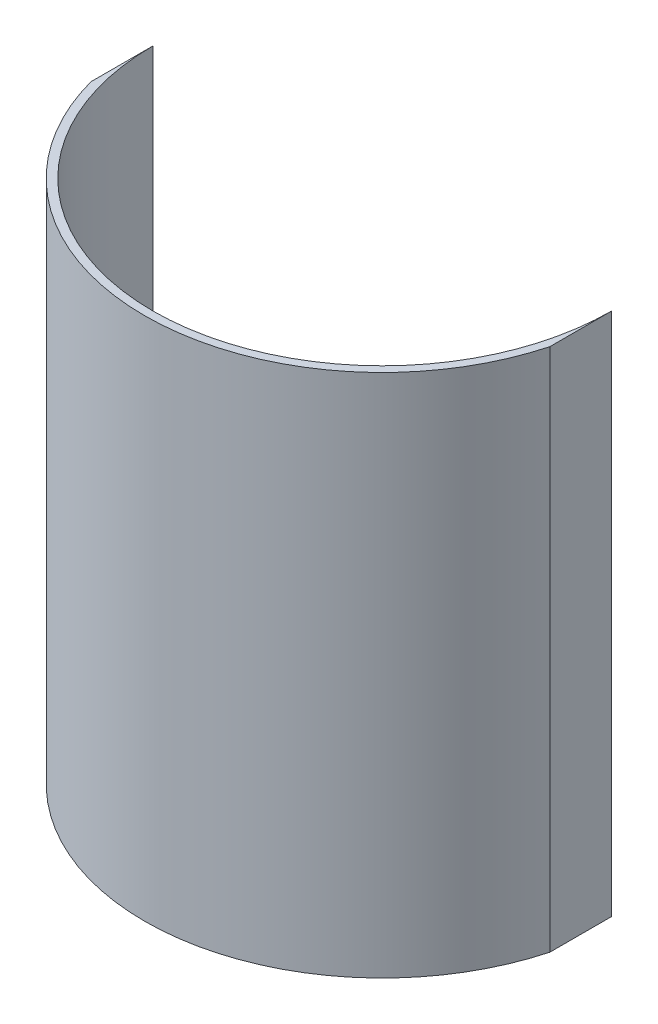
from build123d import *

# Parameters (mm, degrees)
BOSS_EXTRUDE2_DEPTH = 203.2


with BuildPart() as part:
    # Sketch3 → Boss-Extrude2 (new body)
    with BuildSketch(Plane(origin=(0, 50.8, 0), x_dir=(1, 0, 0), z_dir=(0, 1, 0))):
        with BuildLine():
            Line((88.9, -23.970724332), (88.9, 0))
            ThreePointArc((88.9, 0), (0, -88.9), (-88.9, 0))
            Line((-88.9, 0), (-88.9, -23.970724332))
            ThreePointArc((-88.9, -23.970724332), (0, -92.075), (88.9, -23.970724332))
        make_face()
    extrude(amount=BOSS_EXTRUDE2_DEPTH)


solid = part.part
